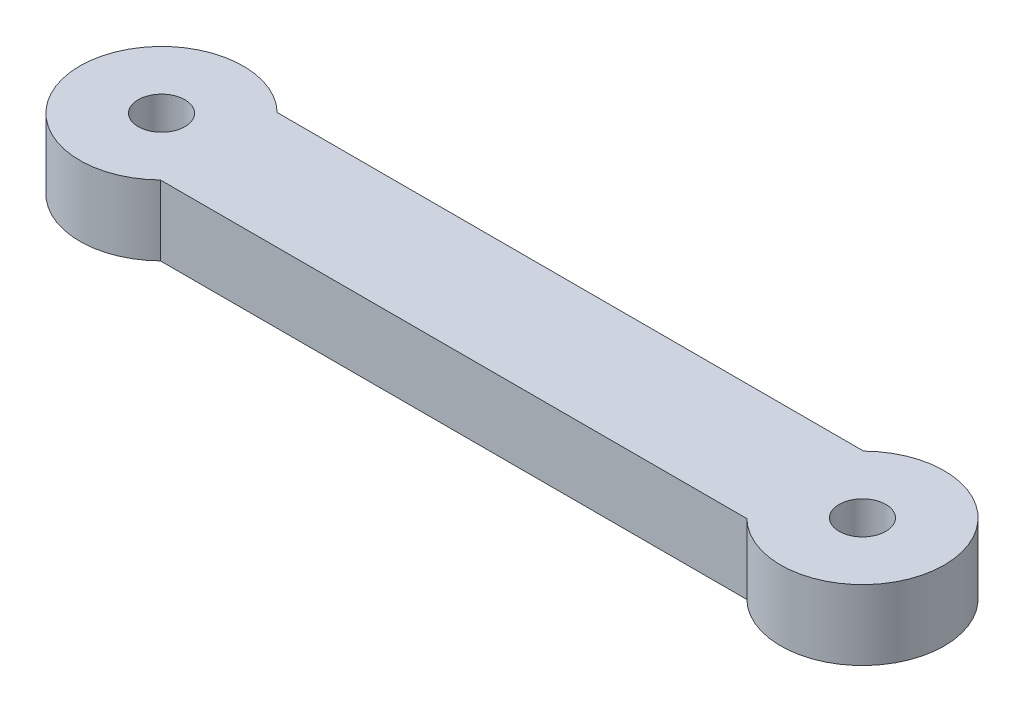
from build123d import *

# Parameters (mm, degrees)
CROQUIS2_R              = 1
SALIENTE_EXTRUIR1_DEPTH = 3


with BuildPart() as part:
    # Croquis2 → Saliente-Extruir1 (new body)
    with BuildSketch(Plane(origin=(0, 0, 0), x_dir=(1, 0, 0), z_dir=(0, 1, 0))):
        with BuildLine():
            Line((-13.360255821, 1.298148445), (11.740764693, 1.298148445))
            ThreePointArc((11.740764693, 1.298148445), (17.690254436, -1.201851555), (11.740764693, -3.701851555))
            Line((11.740764693, -3.701851555), (-13.360255821, -3.701851555))
            ThreePointArc((-13.360255821, -3.701851555), (-19.309745564, -1.201851555), (-13.360255821, 1.298148445))
        make_face()
        with Locations((-15.809745564, -1.201851555)):
            Circle(CROQUIS2_R, mode=Mode.SUBTRACT)
        with Locations((14.190254436, -1.201851555)):
            Circle(CROQUIS2_R, mode=Mode.SUBTRACT)
    extrude(amount=SALIENTE_EXTRUIR1_DEPTH)


solid = part.part
